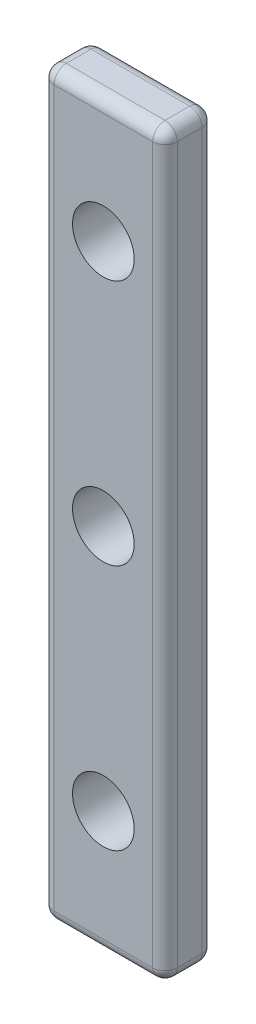
from build123d import *

# Parameters (mm, degrees)
SKETCH2_W           = 10
SKETCH2_H           = 60
SKETCH2_R           = 2.5
BOSS_EXTRUDE1_DEPTH = 4
FILLET1_R           = 1


with BuildPart() as part:
    # Sketch2 → Boss-Extrude1 (new body)
    with BuildSketch(Plane.XY):
        with Locations((5, 30)):
            Rectangle(SKETCH2_W, SKETCH2_H)
        with Locations((5, 50)):
            Circle(SKETCH2_R, mode=Mode.SUBTRACT)
        with Locations((5, 10)):
            Circle(SKETCH2_R, mode=Mode.SUBTRACT)
        with Locations((5, 30)):
            Circle(SKETCH2_R, mode=Mode.SUBTRACT)
    extrude(amount=BOSS_EXTRUDE1_DEPTH)

    # Fillet1
    fillet1_edges = [part.edges().sort_by_distance(p)[0] for p in [
        (10, 30, 4),
        (5, 60, 4),
        (0, 30, 4),
        (5, 60, 0),
        (10, 30, 0),
        (5, 0, 0),
        (0, 30, 0),
        (0, 60, 2),
        (10, 60, 2),
        (10, 0, 2),
        (0, 0, 2),
        (5, 0, 4),
    ]]
    fillet(fillet1_edges, radius=FILLET1_R)


solid = part.part
